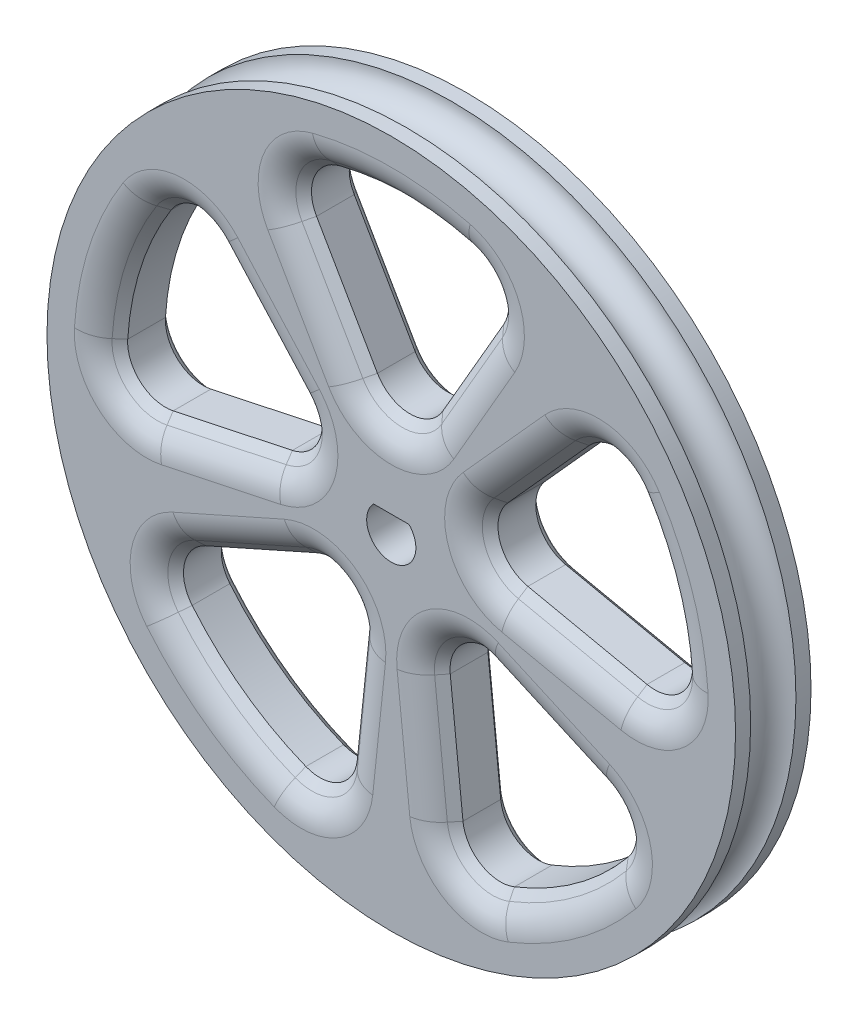
from build123d import *

# Parameters (mm, degrees)
SKETCH1_R                    = 23.1775
BOSS_EXTRUDE1_DEPTH          = 5.08
CUT_EXTRUDE3_DEPTH           = 5.08
FILLET3_R                    = 2.54
CHAMFER2_SIZE                = 1.27
CIRPATTERN3_COUNT            = 5
FILLET3_OF_CIRPATTERN3_R     = 2.54
CHAMFER2_OF_CIRPATTERN3_SIZE = 1.27
CUT_EXTRUDE4_DEPTH           = 5.08
FILLET4_R                    = 2.54


with BuildPart() as part:
    # Sketch1 → Boss-Extrude1 (new body)
    with BuildSketch(Plane.XY):
        Circle(SKETCH1_R)
    extrude(amount=BOSS_EXTRUDE1_DEPTH)

    # Sketch2 → Cut-Extrude3 (cut)
    with BuildSketch(Plane.XY.offset(5.08)):
        with BuildLine():
            Line((0, 3.81), (7.827476944, 17.367587762))
            ThreePointArc((7.827476944, 17.367587762), (0, 19.05), (-7.827476944, 17.367587762))
            Line((-7.827476944, 17.367587762), (0, 3.81))
        make_face()
    cut_extrude3 = extrude(amount=-CUT_EXTRUDE3_DEPTH, mode=Mode.SUBTRACT)

    # Fillet3
    fillet3_edges = [part.edges().sort_by_distance(p)[0] for p in [
        (7.827476944, 17.367587762, 2.54),
        (0, 3.81, 2.54),
        (-7.827476944, 17.367587762, 2.54),
    ]]
    fillet(fillet3_edges, radius=FILLET3_R)

    # Chamfer2
    chamfer2_edges = [part.edges().sort_by_distance(p)[0] for p in [
        (4.250057994, 11.17131638, 0),
        (4.250057994, 11.17131638, 5.08),
        (-4.250057994, 11.17131638, 5.08),
        (-4.250057994, 11.17131638, 0),
        (0, 19.05, 0),
        (0, 19.05, 5.08),
        (0, 6.35, 5.08),
        (0, 6.35, 0),
        (-6.442080419, 16.977300326, 5.08),
        (-6.442080419, 16.977300326, 0),
        (6.442080419, 16.977300326, 5.08),
        (6.442080419, 16.977300326, 0),
    ]]
    chamfer(chamfer2_edges, length=CHAMFER2_SIZE)

    # CirPattern3: Cut-Extrude3 ×5 about axis
    cirpattern3_axis = Axis((0, 0, 0), (0, 0, 1))
    for i in range(1, CIRPATTERN3_COUNT):
        add(cut_extrude3.rotate(cirpattern3_axis, i * 360 / CIRPATTERN3_COUNT), mode=Mode.SUBTRACT)

    # Fillet3 of CirPattern3
    fillet3_of_cirpattern3_edges = [part.edges().sort_by_distance(p)[0] for p in [
        (-14.098734115, 12.811252724, 2.54),
        (-3.623525327, 1.177354749, 2.54),
        (-18.936380913, -2.077493184, 2.54),
        (-16.540973826, -9.449798141, 2.54),
        (-2.239461811, -3.082354749, 2.54),
        (-3.875850084, -18.651549162, 2.54),
        (3.875850084, -18.651549162, 2.54),
        (2.239461811, -3.082354749, 2.54),
        (16.540973826, -9.449798141, 2.54),
        (18.936380913, -2.077493184, 2.54),
        (3.623525327, 1.177354749, 2.54),
        (14.098734115, 12.811252724, 2.54),
    ]]
    fillet(fillet3_of_cirpattern3_edges, radius=FILLET3_OF_CIRPATTERN3_R)

    # Chamfer2 of CirPattern3
    chamfer2_of_cirpattern3_edges = [part.edges().sort_by_distance(p)[0] for p in [
        (-9.311213092, 7.494171961, 0),
        (-9.311213092, 7.494171961, 5.08),
        (-11.937893386, -0.589918739, 5.08),
        (-11.937893386, -0.589918739, 0),
        (-18.117626635, 5.886773743, 0),
        (-18.117626635, 5.886773743, 5.08),
        (-6.039208878, 1.962257914, 5.08),
        (-6.039208878, 1.962257914, 0),
        (-18.137084433, -0.880508242, 5.08),
        (-18.137084433, -0.880508242, 0),
        (-14.155659776, 11.373056881, 5.08),
        (-14.155659776, 11.373056881, 0),
        (-10.004704161, -6.539663391, 0),
        (-10.004704161, -6.539663391, 5.08),
        (-3.127965873, -11.535906211, 5.08),
        (-3.127965873, -11.535906211, 0),
        (-11.197309056, -15.411773743, 0),
        (-11.197309056, -15.411773743, 5.08),
        (-3.732436352, -5.137257914, 5.08),
        (-3.732436352, -5.137257914, 0),
        (-4.767254217, -17.521484347, 5.08),
        (-4.767254217, -17.521484347, 0),
        (-15.190759294, -9.948364618, 5.08),
        (-15.190759294, -9.948364618, 0),
        (3.127965873, -11.535906211, 0),
        (3.127965873, -11.535906211, 5.08),
        (10.004704161, -6.539663391, 5.08),
        (10.004704161, -6.539663391, 0),
        (11.197309056, -15.411773743, 0),
        (11.197309056, -15.411773743, 5.08),
        (3.732436352, -5.137257914, 5.08),
        (3.732436352, -5.137257914, 0),
        (15.190759294, -9.948364618, 5.08),
        (15.190759294, -9.948364618, 0),
        (4.767254217, -17.521484347, 5.08),
        (4.767254217, -17.521484347, 0),
        (11.937893386, -0.589918739, 0),
        (11.937893386, -0.589918739, 5.08),
        (9.311213092, 7.494171961, 5.08),
        (9.311213092, 7.494171961, 0),
        (18.117626635, 5.886773743, 0),
        (18.117626635, 5.886773743, 5.08),
        (6.039208878, 1.962257914, 5.08),
        (6.039208878, 1.962257914, 0),
        (14.155659776, 11.373056881, 5.08),
        (14.155659776, 11.373056881, 0),
        (18.137084433, -0.880508242, 5.08),
        (18.137084433, -0.880508242, 0),
    ]]
    chamfer(chamfer2_of_cirpattern3_edges, length=CHAMFER2_OF_CIRPATTERN3_SIZE)

    # Sketch5 → Cut-Extrude4 (cut)
    with BuildSketch(Plane.XY.offset(5.08)):
        with BuildLine():
            ThreePointArc((1.19791499, 1.143749935), (0, -1.656250053), (-1.19791499, 1.143749935))
            Line((-1.19791499, 1.143749935), (1.19791499, 1.143749935))
        make_face()
    extrude(amount=-CUT_EXTRUDE4_DEPTH, mode=Mode.SUBTRACT)

    # Fillet4
    fillet4_edges = [part.edges().sort_by_distance(p)[0] for p in [
        (-18.967083783, -1.84175799, 5.08),
        (-19.325468411, 6.279225326, 5.08),
        (-11.673845539, -1.832166191, 5.08),
        (-4.831367103, 1.569806331, 5.08),
        (-8.367419164, 8.343967831, 5.08),
        (-14.26213493, 12.63858564, 5.08),
        (-19.325468411, 6.279225326, 0),
        (-18.967083783, -1.84175799, 0),
        (-11.673845539, -1.832166191, 0),
        (-4.831367103, 1.569806331, 0),
        (-8.367419164, 8.343967831, 0),
        (-14.26213493, 12.63858564, 0),
        (-4.109535285, -18.607903146, 5.08),
        (-11.943796327, -16.439225326, 5.08),
        (-1.864923066, -11.66865736, 5.08),
        (-2.985949082, -4.109806331, 5.08),
        (-10.521259698, -5.37946066, 5.08),
        (-16.427251299, -9.658558614, 5.08),
        (-11.943796327, -16.439225326, 0),
        (-4.109535285, -18.607903146, 0),
        (-1.864923066, -11.66865736, 0),
        (-2.985949082, -4.109806331, 0),
        (-10.521259698, -5.37946066, 0),
        (-16.427251299, -9.658558614, 0),
        (16.427251299, -9.658558614, 5.08),
        (11.943796327, -16.439225326, 5.08),
        (10.521259698, -5.37946066, 5.08),
        (2.985949082, -4.109806331, 5.08),
        (1.864923066, -11.66865736, 5.08),
        (4.109535285, -18.607903146, 5.08),
        (11.943796327, -16.439225326, 0),
        (16.427251299, -9.658558614, 0),
        (10.521259698, -5.37946066, 0),
        (2.985949082, -4.109806331, 0),
        (1.864923066, -11.66865736, 0),
        (4.109535285, -18.607903146, 0),
        (14.26213493, 12.63858564, 5.08),
        (19.325468411, 6.279225326, 5.08),
        (8.367419164, 8.343967831, 5.08),
        (4.831367103, 1.569806331, 5.08),
        (11.673845539, -1.832166191, 5.08),
        (18.967083783, -1.84175799, 5.08),
        (19.325468411, 6.279225326, 0),
        (14.26213493, 12.63858564, 0),
        (8.367419164, 8.343967831, 0),
        (4.831367103, 1.569806331, 0),
        (11.673845539, -1.832166191, 0),
        (18.967083783, -1.84175799, 0),
        (-7.61276716, 17.469634109, 5.08),
        (0, 20.32, 5.08),
        (-5.349910257, 10.53631638, 5.08),
        (0, 5.08, 5.08),
        (5.349910257, 10.53631638, 5.08),
        (7.61276716, 17.469634109, 5.08),
        (0, 20.32, 0),
        (-7.61276716, 17.469634109, 0),
        (-5.349910257, 10.53631638, 0),
        (0, 5.08, 0),
        (5.349910257, 10.53631638, 0),
        (7.61276716, 17.469634109, 0),
    ]]
    fillet(fillet4_edges, radius=FILLET4_R)

    # Sketch7 → Cut-Revolve1 (revolve, cut)
    with BuildSketch(Plane(origin=(0, 0, 0), x_dir=(1, 0, 0), z_dir=(0, 1, 0))):
        with BuildLine():
            Line((-23.1775, -4.064), (-23.1775, -1.016))
            ThreePointArc((-23.1775, -1.016), (-21.6535, -2.54), (-23.1775, -4.064))
        make_face()
    revolve(axis=Axis((0, 0, 0), (0, 0, -1)), mode=Mode.SUBTRACT)


solid = part.part
